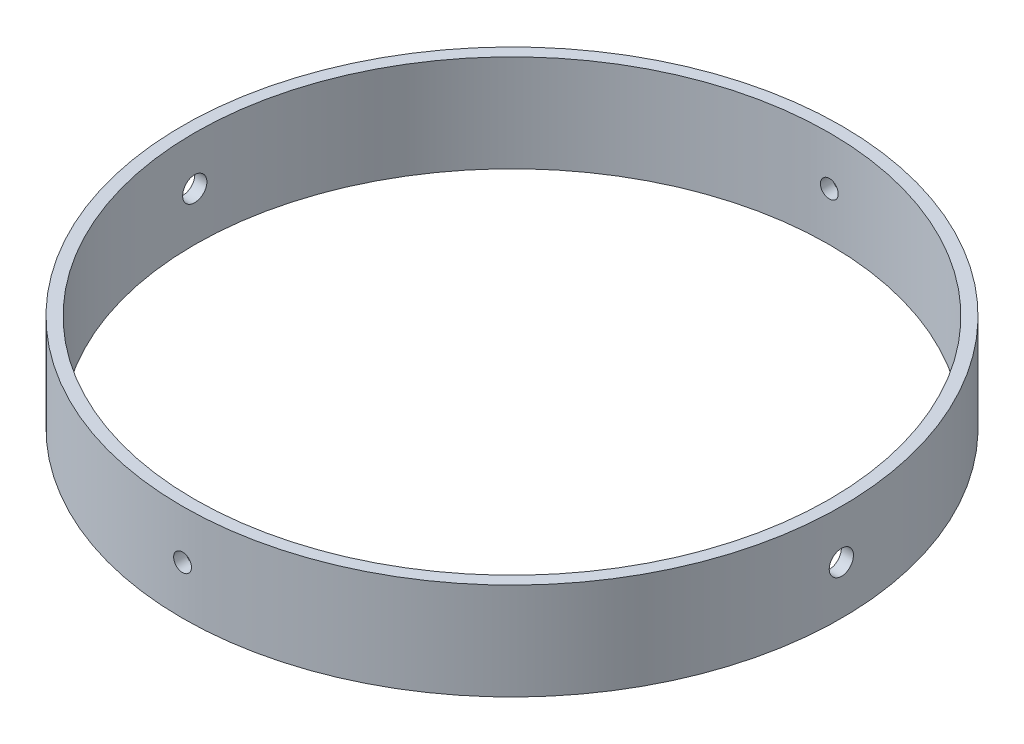
from build123d import *

# Parameters (mm, degrees)
SKETCH1_R               = 86.36
SKETCH1_R_2             = 83.185
BOSS_EXTRUDE1_DEPTH     = 25.4
SKETCH2_R               = 3.175
CUT_EXTRUDE1_DEPTH      = 87.36
CUT_EXTRUDE1_DEPTH_BACK = 87.36
SKETCH3_R               = 2.3368
CUT_EXTRUDE2_DEPTH      = 87.3600001
CUT_EXTRUDE2_DEPTH_BACK = 87.3600001


with BuildPart() as part:
    # Sketch1 → Boss-Extrude1 (new body)
    with BuildSketch(Plane(origin=(0, 0, 0), x_dir=(1, 0, 0), z_dir=(0, 1, 0))):
        Circle(SKETCH1_R)
        Circle(SKETCH1_R_2, mode=Mode.SUBTRACT)
    extrude(amount=BOSS_EXTRUDE1_DEPTH)

    # Sketch2 → Cut-Extrude1 (cut, two sides)
    with BuildSketch(Plane(origin=(0, 0, 0), x_dir=(0, 0, -1), z_dir=(1, 0, 0))) as cut_extrude1_sk:
        with Locations((0, 12.7)):
            Circle(SKETCH2_R)
    extrude(amount=CUT_EXTRUDE1_DEPTH, mode=Mode.SUBTRACT)
    extrude(cut_extrude1_sk.sketch, amount=-CUT_EXTRUDE1_DEPTH_BACK, mode=Mode.SUBTRACT)

    # Sketch3 → Cut-Extrude2 (cut, two sides)
    with BuildSketch(Plane.XY) as cut_extrude2_sk:
        with Locations((0, 12.7)):
            Circle(SKETCH3_R)
    extrude(amount=CUT_EXTRUDE2_DEPTH, mode=Mode.SUBTRACT)
    extrude(cut_extrude2_sk.sketch, amount=-CUT_EXTRUDE2_DEPTH_BACK, mode=Mode.SUBTRACT)


solid = part.part
